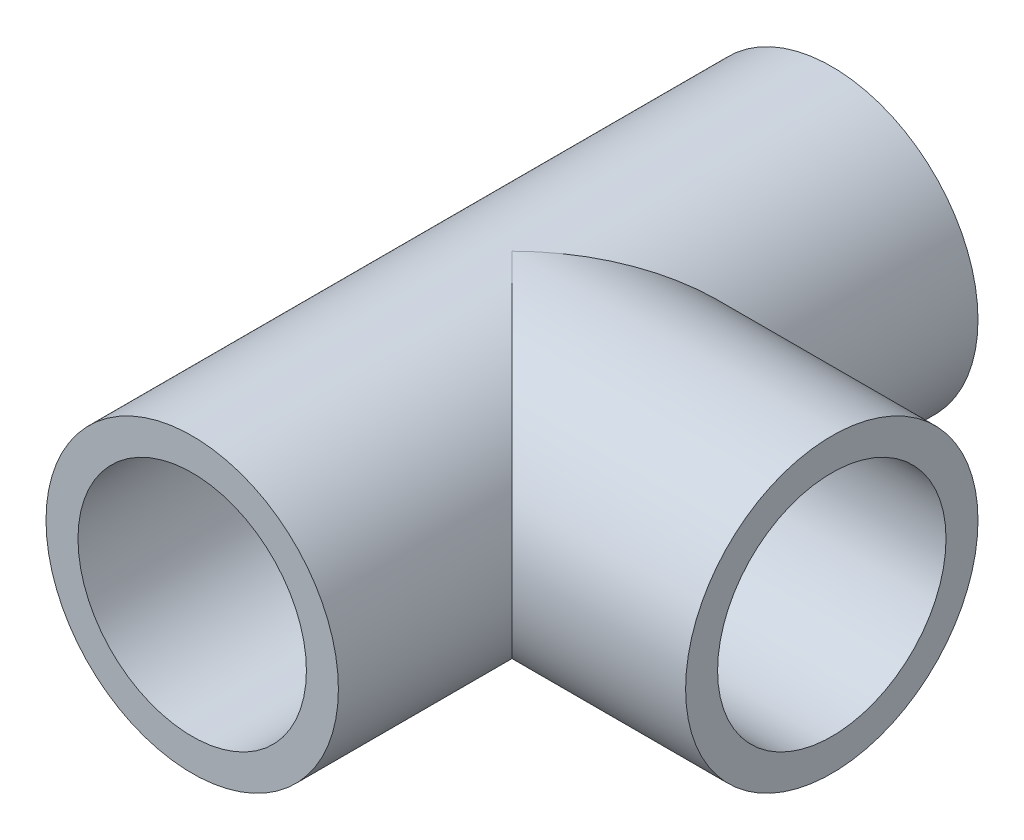
from build123d import *

# Parameters (mm, degrees)
SKETCH_1_R      = 16
SKETCH_1_R_2    = 12.5
EXTRUDE_1_DEPTH = 35
SKETCH_2_R      = 16
SKETCH_2_R_2    = 12.5
EXTRUDE_2_DEPTH = 35


with BuildPart() as part:
    # 草图1 → 凸台-拉伸1 (new body, symmetric)
    with BuildSketch(Plane.XY):
        Circle(SKETCH_1_R)
        Circle(SKETCH_1_R_2, mode=Mode.SUBTRACT)
    extrude(amount=EXTRUDE_1_DEPTH, both=True)

    # 草图2 → 凸台-拉伸2 (add)
    with BuildSketch(Plane(origin=(0, 0, 0), x_dir=(0, 0, -1), z_dir=(1, 0, 0))):
        Circle(SKETCH_2_R)
        Circle(SKETCH_2_R_2, mode=Mode.SUBTRACT)
    extrude(amount=EXTRUDE_2_DEPTH)


solid = part.part
